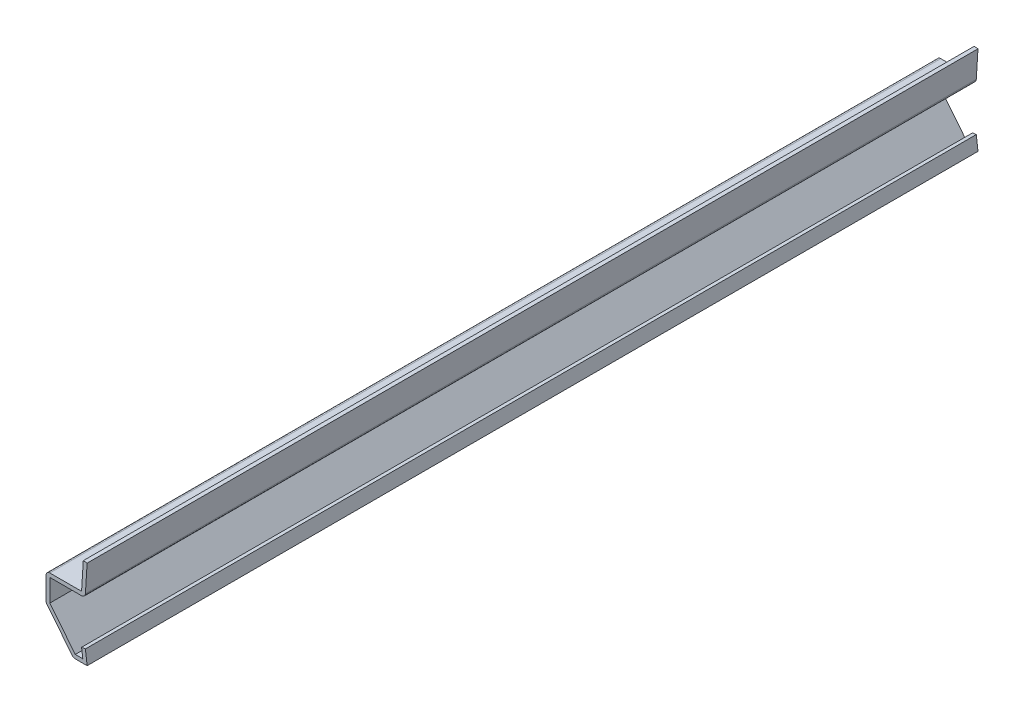
from build123d import *

# Parameters (mm, degrees)
EXTRUDE_THIN1_DEPTH = 206.375
FILLET1_R           = 0.889


with BuildPart() as part:
    # Sketch1 → Extrude-Thin1 (new body)
    with BuildSketch(Plane.XY):
        Polygon((-0.396875, 3.175), (0, 0), (-3.175, 0), (-9.525, 7.9375), (-9.525, 14.2875), (-1.285875, 14.2875), (-0.889, 20.6375), (-0.001731258, 20.582045704), (-0.450702864, 13.3985), (-8.636, 13.3985), (-8.636, 8.249344362), (-2.747724511, 0.889), (-1.007043392, 0.889), (-1.279010032, 3.064733121), align=None)
    extrude(amount=-EXTRUDE_THIN1_DEPTH)

    # Fillet1
    fillet1_edges = [part.edges().sort_by_distance(p)[0] for p in [
        (-0.450702864, 13.3985, -103.1875),
        (-3.175, 0, -103.1875),
        (-9.525, 7.9375, -103.1875),
        (-9.525, 14.2875, -103.1875),
    ]]
    fillet(fillet1_edges, radius=FILLET1_R)


solid = part.part
